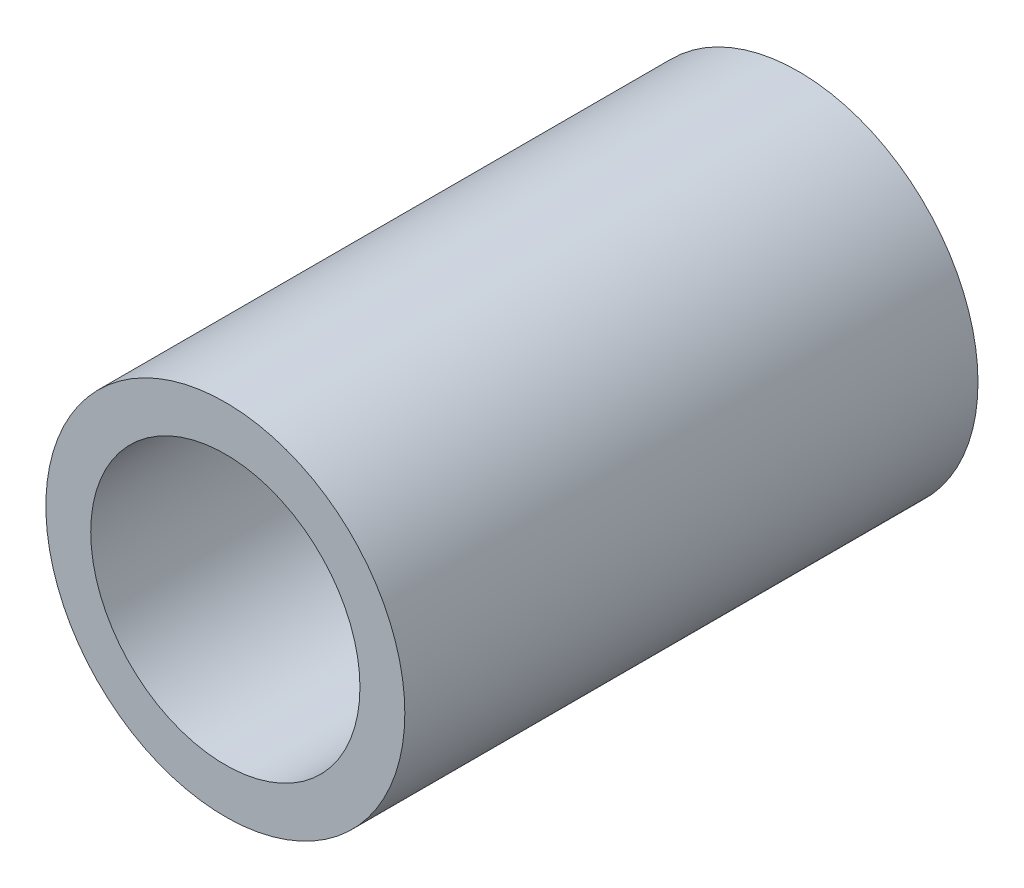
from build123d import *

# Parameters (mm, degrees)
SKETCH3_R           = 38.1
SKETCH3_R_2         = 28.575
BOSS_EXTRUDE1_DEPTH = 60.833


with BuildPart() as part:
    # Sketch3 → Boss-Extrude1 (new, symmetric)
    with BuildSketch(Plane.XY):
        Circle(SKETCH3_R)
        Circle(SKETCH3_R_2, mode=Mode.SUBTRACT)
    extrude(amount=BOSS_EXTRUDE1_DEPTH, both=True)


solid = part.part
